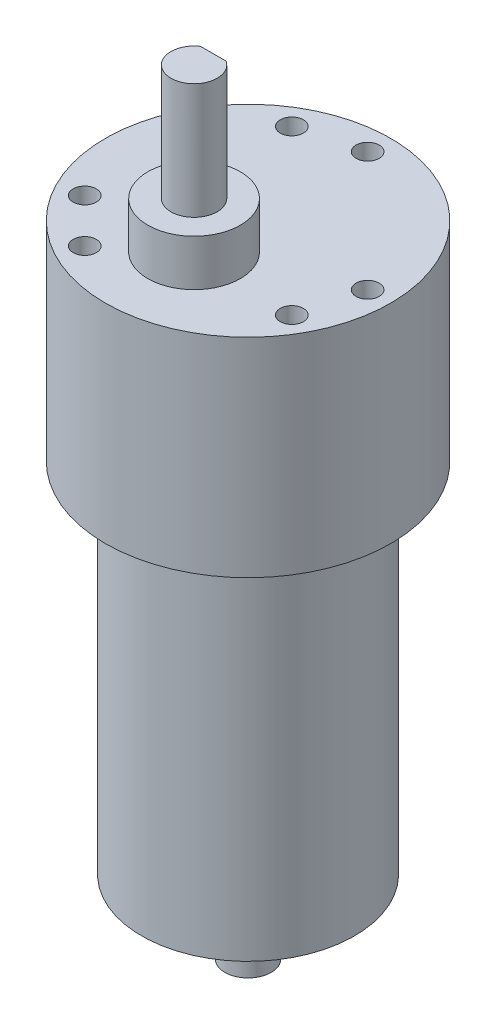
from build123d import *

# Parameters (mm, degrees)
SKETCH1_R           = 18.5
BOSS_EXTRUDE1_DEPTH = 27
SKETCH2_R           = 1.5
CUT_EXTRUDE1_DEPTH  = 5
CIRPATTERN1_COUNT   = 3
SKETCH3_R           = 6
BOSS_EXTRUDE2_DEPTH = 6
SKETCH4_R           = 3
BOSS_EXTRUDE3_DEPTH = 15
CUT_EXTRUDE2_DEPTH  = 12
SKETCH6_R           = 13.8
BOSS_EXTRUDE4_DEPTH = 46.4
SKETCH7_R           = 3
BOSS_EXTRUDE5_DEPTH = 9.5


with BuildPart() as part:
    # Sketch1 → Boss-Extrude1 (new body)
    with BuildSketch(Plane(origin=(0, 0, 0), x_dir=(1, 0, 0), z_dir=(0, 1, 0))):
        Circle(SKETCH1_R)
    extrude(amount=BOSS_EXTRUDE1_DEPTH)

    # Sketch2 → Cut-Extrude1 (cut)
    with BuildSketch(Plane(origin=(0, 27, 0), x_dir=(1, 0, 0), z_dir=(0, 1, 0))):
        with Locations((0, 15.5)):
            Circle(SKETCH2_R)
        with Locations((-7.75, 13.423393759)):
            Circle(SKETCH2_R)
    cut_extrude1 = extrude(amount=-CUT_EXTRUDE1_DEPTH, mode=Mode.SUBTRACT)

    # CirPattern1: Cut-Extrude1 ×3 about axis
    cirpattern1_axis = Axis((0, 0, 0), (0, 1, 0))
    for i in range(1, CIRPATTERN1_COUNT):
        add(cut_extrude1.rotate(cirpattern1_axis, i * 360 / CIRPATTERN1_COUNT), mode=Mode.SUBTRACT)

    # Sketch3 → Boss-Extrude2 (add)
    with BuildSketch(Plane(origin=(0, 27, 0), x_dir=(1, 0, 0), z_dir=(0, 1, 0))):
        with Locations((0, -7)):
            Circle(SKETCH3_R)
    extrude(amount=BOSS_EXTRUDE2_DEPTH)

    # Sketch4 → Boss-Extrude3 (add)
    with BuildSketch(Plane(origin=(0, 33, 0), x_dir=(1, 0, 0), z_dir=(0, 1, 0))):
        with Locations((0, -7)):
            Circle(SKETCH4_R)
    extrude(amount=BOSS_EXTRUDE3_DEPTH)

    # Sketch5 → Cut-Extrude2 (cut)
    with BuildSketch(Plane(origin=(0, 48, 0), x_dir=(1, 0, 0), z_dir=(0, 1, 0))):
        with BuildLine():
            Line((-1.658312395, -4.5), (1.658312395, -4.5))
            ThreePointArc((1.658312395, -4.5), (0, -4), (-1.658312395, -4.5))
        make_face()
    extrude(amount=-CUT_EXTRUDE2_DEPTH, mode=Mode.SUBTRACT)

    # Sketch6 → Boss-Extrude4 (add)
    with BuildSketch(Plane.XZ):
        Circle(SKETCH6_R)
    extrude(amount=BOSS_EXTRUDE4_DEPTH)

    # Sketch7 → Boss-Extrude5 (add)
    with BuildSketch(Plane.XZ.offset(46.4)):
        Circle(SKETCH7_R)
    extrude(amount=BOSS_EXTRUDE5_DEPTH)


solid = part.part
